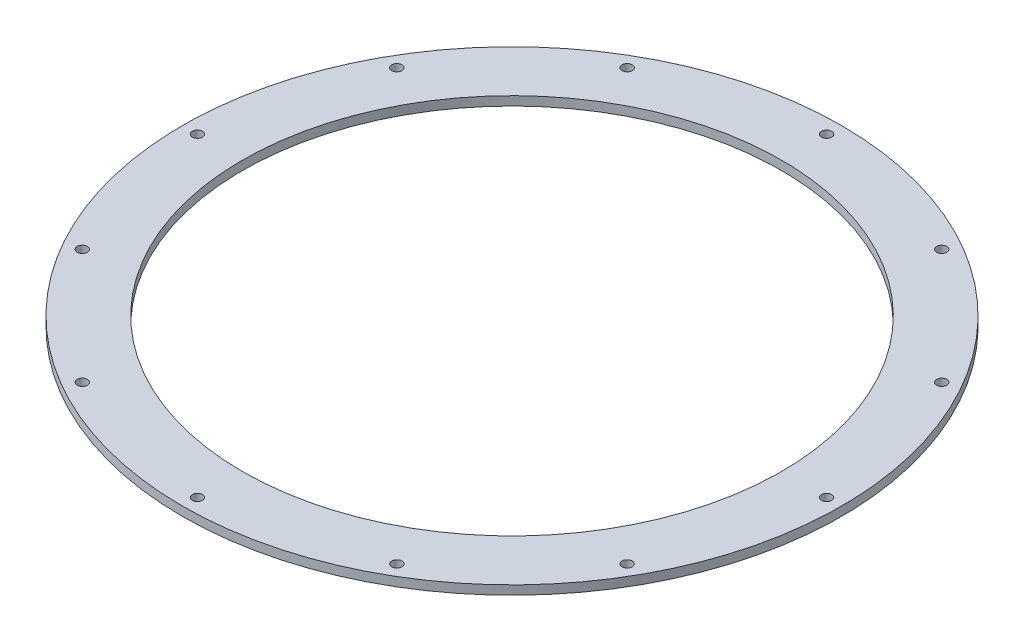
from build123d import *

# Parameters (mm, degrees)
SKETCH1_R           = 110
SKETCH1_R_2         = 90
SKETCH1_R_3         = 1.7
BOSS_EXTRUDE1_DEPTH = 3


with BuildPart() as part:
    # Sketch1 → Boss-Extrude1 (new body)
    with BuildSketch(Plane(origin=(0, 0, 0), x_dir=(1, 0, 0), z_dir=(0, 1, 0))):
        Circle(SKETCH1_R)
        Circle(SKETCH1_R_2, mode=Mode.SUBTRACT)
        with Locations((0, 105)):
            Circle(SKETCH1_R_3, mode=Mode.SUBTRACT)
        with Locations((52.5, 90.932667397)):
            Circle(SKETCH1_R_3, mode=Mode.SUBTRACT)
        with Locations((90.932667397, 52.5)):
            Circle(SKETCH1_R_3, mode=Mode.SUBTRACT)
        with Locations((105, 0)):
            Circle(SKETCH1_R_3, mode=Mode.SUBTRACT)
        with Locations((90.932667397, -52.5)):
            Circle(SKETCH1_R_3, mode=Mode.SUBTRACT)
        with Locations((52.5, -90.932667397)):
            Circle(SKETCH1_R_3, mode=Mode.SUBTRACT)
        with Locations((0, -105)):
            Circle(SKETCH1_R_3, mode=Mode.SUBTRACT)
        with Locations((-52.5, -90.932667397)):
            Circle(SKETCH1_R_3, mode=Mode.SUBTRACT)
        with Locations((-90.932667397, -52.5)):
            Circle(SKETCH1_R_3, mode=Mode.SUBTRACT)
        with Locations((-105, 0)):
            Circle(SKETCH1_R_3, mode=Mode.SUBTRACT)
        with Locations((-90.932667397, 52.5)):
            Circle(SKETCH1_R_3, mode=Mode.SUBTRACT)
        with Locations((-52.5, 90.932667397)):
            Circle(SKETCH1_R_3, mode=Mode.SUBTRACT)
    extrude(amount=BOSS_EXTRUDE1_DEPTH)


solid = part.part
